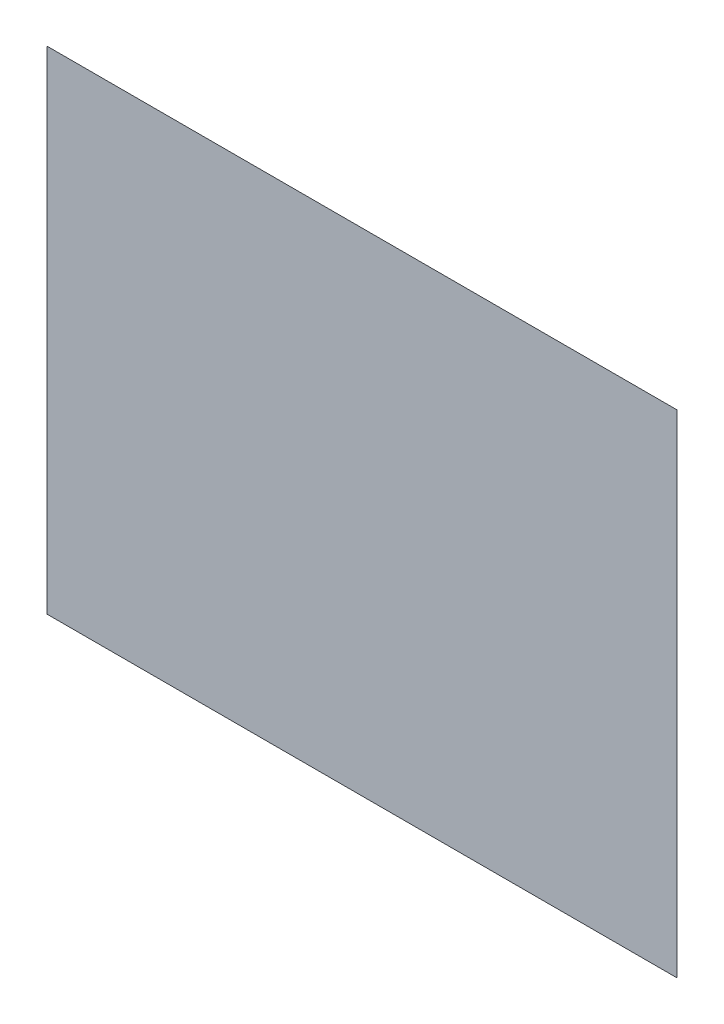
from build123d import *

# Parameters (mm, degrees)
SKETCH_2_W = 335
SKETCH_2_H = 261.4
SKETCH_1_W = 135
SKETCH_1_H = 125


with BuildPart() as part:
    # 草图2 → 放样1 section 0
    with BuildSketch(Plane.XY.offset(100)):
        with Locations((45.004396333, 95.696179637)):
            Rectangle(SKETCH_2_W, SKETCH_2_H)
    # 草图1 → 放样1 section 1
    with BuildSketch(Plane.XY):
        with Locations((45.004396333, 63.896179637)):
            Rectangle(SKETCH_1_W, SKETCH_1_H)
    loft()


solid = part.part
